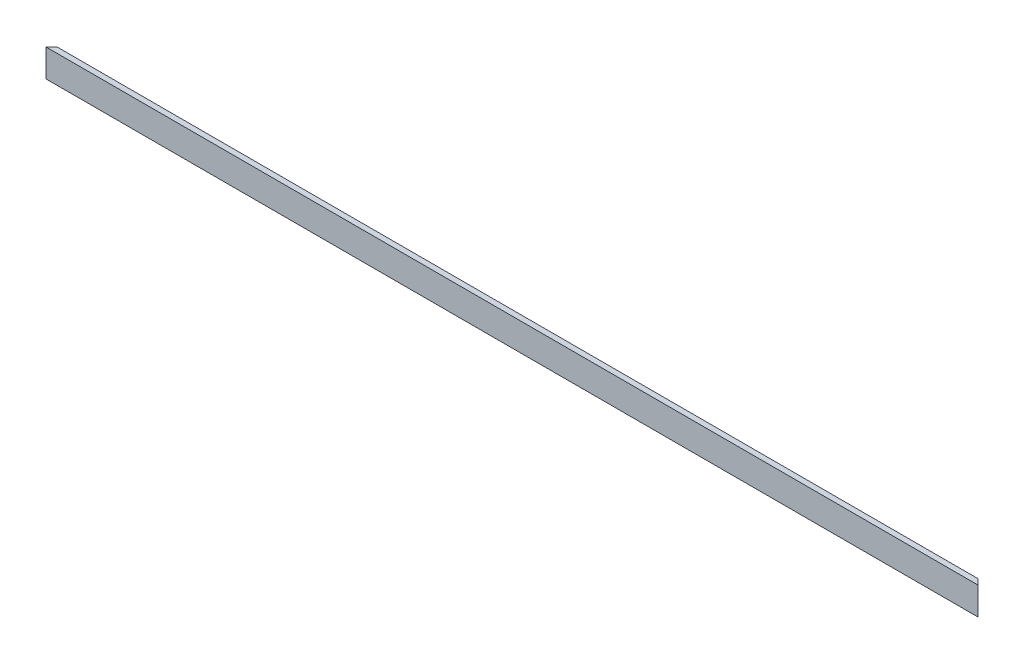
from build123d import *

# Parameters (mm, degrees)
SKETCH1_W           = 6406.963073453
SKETCH1_H           = 190.5
BOSS_EXTRUDE1_DEPTH = 38.1
CUT_EXTRUDE1_DEPTH  = 190.5


with BuildPart() as part:
    # Sketch1 → Boss-Extrude1 (new body)
    with BuildSketch(Plane.XY):
        with Locations((3203.481536727, 95.25)):
            Rectangle(SKETCH1_W, SKETCH1_H)
    extrude(amount=BOSS_EXTRUDE1_DEPTH)

    # Sketch2 → Cut-Extrude1 (cut)
    with BuildSketch(Plane(origin=(0, 190.5, 0), x_dir=(1, 0, 0), z_dir=(0, 1, 0))):
        Polygon((0, -38.1), (38.1, 0), (0, 0), align=None)
        Polygon((6406.963073453, -38.1), (6368.863073453, 0), (6406.963073453, 0), align=None)
    extrude(amount=-CUT_EXTRUDE1_DEPTH, mode=Mode.SUBTRACT)


solid = part.part
